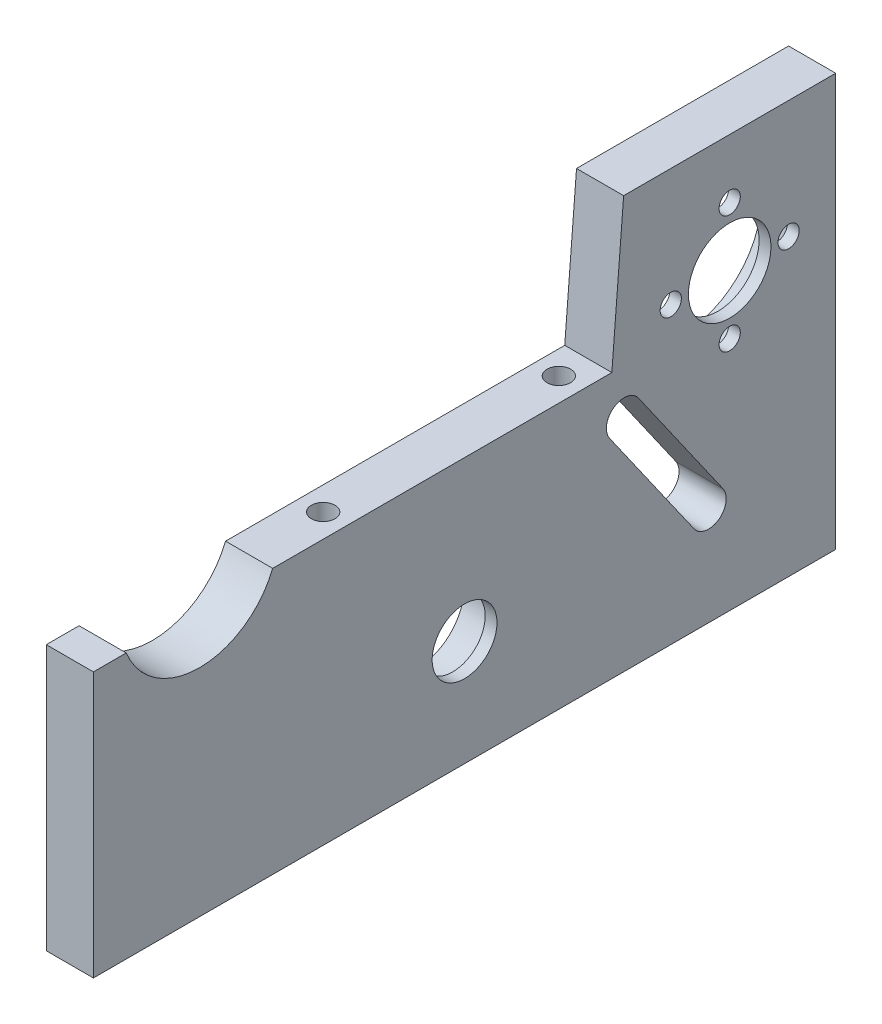
from build123d import *

# Parameters (mm, degrees)
ESQUISSE2_W             = 8
ESQUISSE2_H             = 95
ESQUISSE2_H_2           = 31
BOSS_EXTRU_1_DEPTH      = 70
ESQUISSE3_R             = 7.95
ENL_V_MAT_EXTRU_1_DEPTH = 10
ESQUISSE4_R             = 13.4
ENL_V_MAT_EXTRU_2_DEPTH = 6
ESQUISSE6_R             = 1.8
ESQUISSE6_R_2           = 7
ENL_V_MAT_EXTRU_3_DEPTH = 10
ESQUISSE7_R             = 2
ENL_V_MAT_EXTRU_4_DEPTH = 15
ENL_V_MAT_EXTRU_5_DEPTH = 10
ESQUISSE9_R             = 13.4
ENL_V_MAT_EXTRU_6_DEPTH = 10
ESQUISSE10_R            = 13.4
ENL_V_MAT_EXTRU_7_DEPTH = 10
ESQUISSE12_R            = 8.1
ESQUISSE12_R_2          = 5.5
BOSS_EXTRU_3_DEPTH      = 2
ESQUISSE13_R            = 2
ENL_V_MAT_EXTRU_8_DEPTH = 15


with BuildPart() as part:
    # Esquisse2 → Boss.-Extru.1 (new body)
    with BuildSketch(Plane(origin=(0, 0, 0), x_dir=(1, 0, 0), z_dir=(0, 1, 0))):
        with Locations((4, 47.5)):
            Rectangle(ESQUISSE2_W, ESQUISSE2_H)
        with Locations((4, -15.5)):
            Rectangle(ESQUISSE2_W, ESQUISSE2_H_2)
    extrude(amount=BOSS_EXTRU_1_DEPTH)

    # Esquisse3 → Enlèv. mat.-Extru.1 (cut)
    with BuildSketch(Plane.ZY):
        with Locations((-32, 18)):
            Circle(ESQUISSE3_R)
    extrude(amount=-ENL_V_MAT_EXTRU_1_DEPTH, mode=Mode.SUBTRACT)

    # Esquisse4 → Enlèv. mat.-Extru.2 (cut)
    with BuildSketch(Plane.ZY):
        with Locations((-77, 50)):
            Circle(ESQUISSE4_R)
    extrude(amount=-ENL_V_MAT_EXTRU_2_DEPTH, mode=Mode.SUBTRACT)

    # Esquisse6 → Enlèv. mat.-Extru.3 (cut)
    with BuildSketch(Plane.ZY):
        with Locations((-77, 60)):
            Circle(ESQUISSE6_R)
        with Locations((-67, 50)):
            Circle(ESQUISSE6_R)
        with Locations((-77, 40)):
            Circle(ESQUISSE6_R)
        with Locations((-87, 50)):
            Circle(ESQUISSE6_R)
        with Locations((-77, 50)):
            Circle(ESQUISSE6_R_2)
    extrude(amount=-ENL_V_MAT_EXTRU_3_DEPTH, mode=Mode.SUBTRACT)

    # Esquisse7 → Enlèv. mat.-Extru.4 (cut)
    with BuildSketch(Plane.XZ):
        with Locations((4, -91)):
            Circle(ESQUISSE7_R)
        with Locations((4, -4)):
            Circle(ESQUISSE7_R)
        with Locations((4, 27)):
            Circle(ESQUISSE7_R)
    extrude(amount=-ENL_V_MAT_EXTRU_4_DEPTH, mode=Mode.SUBTRACT)

    # Esquisse8 → Enlèv. mat.-Extru.5 (cut)
    with BuildSketch(Plane.ZY):
        with BuildLine():
            Line((-61.528438992, 38.971206009), (-75.867849901, 18.492404902))
            ThreePointArc((-75.867849901, 18.492404902), (-75.131123077, 14.31421946), (-70.952937635, 15.050946284))
            Line((-70.952937635, 15.050946284), (-56.613526727, 35.529747391))
            ThreePointArc((-56.613526727, 35.529747391), (-57.35025355, 39.707932833), (-61.528438992, 38.971206009))
        make_face()
    extrude(amount=-ENL_V_MAT_EXTRU_5_DEPTH, mode=Mode.SUBTRACT)

    # Esquisse9 → Enlèv. mat.-Extru.6 (cut)
    with BuildSketch(Plane.ZY):
        with Locations((13, 50)):
            Circle(ESQUISSE9_R)
    extrude(amount=-ENL_V_MAT_EXTRU_6_DEPTH, mode=Mode.SUBTRACT)

    # Esquisse10 → Enlèv. mat.-Extru.7 (cut)
    with BuildSketch(Plane.ZY):
        with Locations((13, 50)):
            Circle(ESQUISSE10_R)
        Polygon((-57, 45), (-59, 70), (31, 70), (31, 45), align=None)
        with BuildLine():
            ThreePointArc((0.567783786, 45), (13, 36.6), (25.432216214, 45))
            Line((25.432216214, 45), (0.567783786, 45))
        make_face()
        with BuildLine():
            Line((0.567783786, 45), (25.432216214, 45))
            ThreePointArc((25.432216214, 45), (26.155829455, 47.453600313), (26.4, 50))
            ThreePointArc((26.4, 50), (10.453600313, 63.155829455), (0.567783786, 45))
        make_face()
    extrude(amount=-ENL_V_MAT_EXTRU_7_DEPTH, mode=Mode.SUBTRACT)

    # Esquisse12 → Boss.-Extru.3 (add)
    with BuildSketch(Plane(origin=(8, 0, 0), x_dir=(0, 0, -1), z_dir=(1, 0, 0))):
        with Locations((32, 18)):
            Circle(ESQUISSE12_R)
        with Locations((32, 18)):
            Circle(ESQUISSE12_R_2, mode=Mode.SUBTRACT)
    extrude(amount=-BOSS_EXTRU_3_DEPTH)

    # Esquisse13 → Enlèv. mat.-Extru.8 (cut)
    with BuildSketch(Plane(origin=(0, 45, 0), x_dir=(1, 0, 0), z_dir=(0, 1, 0))):
        with Locations((4, 12)):
            Circle(ESQUISSE13_R)
        with Locations((4, 52)):
            Circle(ESQUISSE13_R)
    extrude(amount=-ENL_V_MAT_EXTRU_8_DEPTH, mode=Mode.SUBTRACT)


solid = part.part
